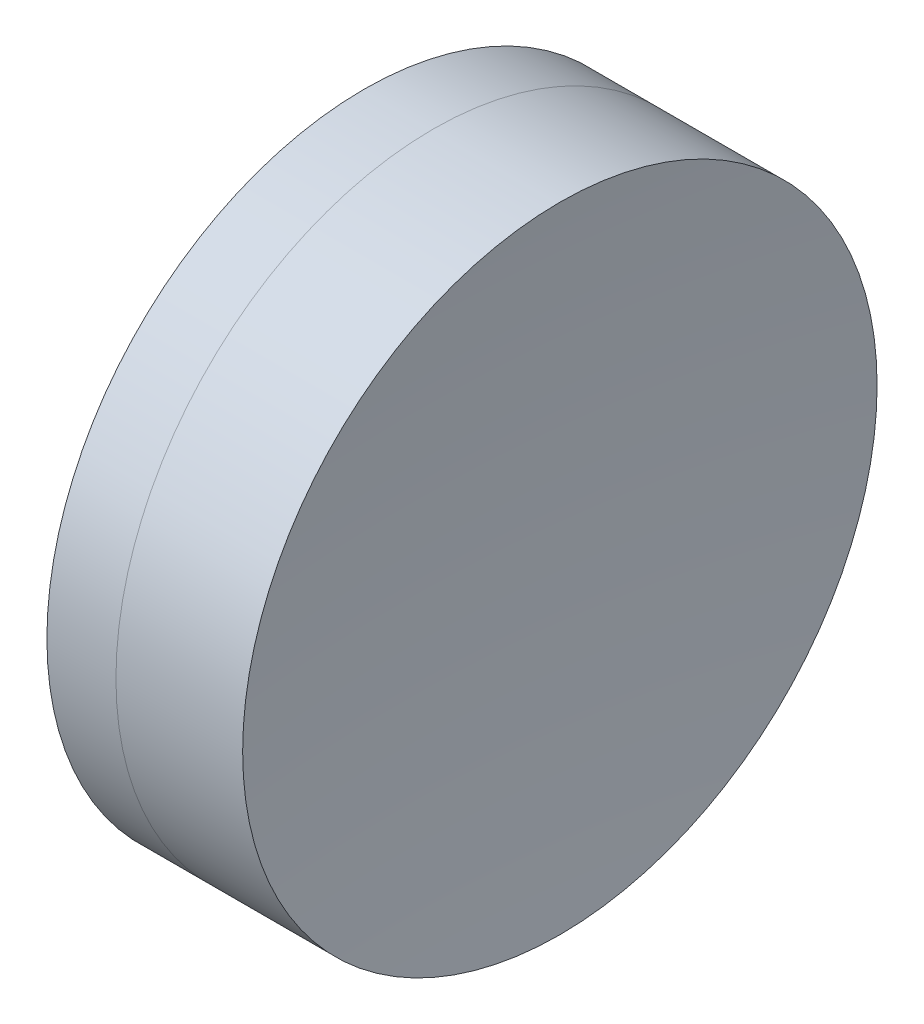
from build123d import *


with BuildPart() as part:
    # 草图1 one side → 旋转1 (revolve)
    with BuildSketch(Plane(origin=(0, 0, 0), x_dir=(1, 0, 0), z_dir=(0, 1, 0)), mode=Mode.PRIVATE) as revolve_1_sk:
        with BuildLine():
            ThreePointArc((37.206715943, 6.35), (36.54422001, 3.205669764), (36.321970472, 0))
            Line((36.321970472, 0), (39.321970472, 0))
            ThreePointArc((39.321970472, 0), (39.138034819, 3.196101111), (38.588656595, 6.35))
            Line((38.588656595, 6.35), (37.206715943, 6.35))
        make_face()
    revolve(revolve_1_sk.sketch.rotate(Axis((-0.816062176, 0, 0), (1, 0, 0)), 180), axis=Axis((-0.816062176, 0, 0), (1, 0, 0)))  # turned: the seam where the file's is


with BuildPart() as body_2:
    # 草图2 one side → 旋转2 (revolve)
    with BuildSketch(Plane(origin=(0, 0, 0), x_dir=(1, 0, 0), z_dir=(0, 1, 0))):
        with BuildLine():
            Line((41.125017394, 6.35), (38.588656595, 6.35))
            ThreePointArc((38.588656595, 6.35), (39.138034819, 3.196101111), (39.321970472, 0))
            Line((39.321970472, 0), (40.821970472, 0))
            ThreePointArc((40.821970472, 0), (40.897775292, 3.178613591), (41.125017394, 6.35))
        make_face()
    revolve(axis=Axis((-0.551919993, 0, 0), (1, 0, 0)))


solid = Compound([part.part, body_2.part])
